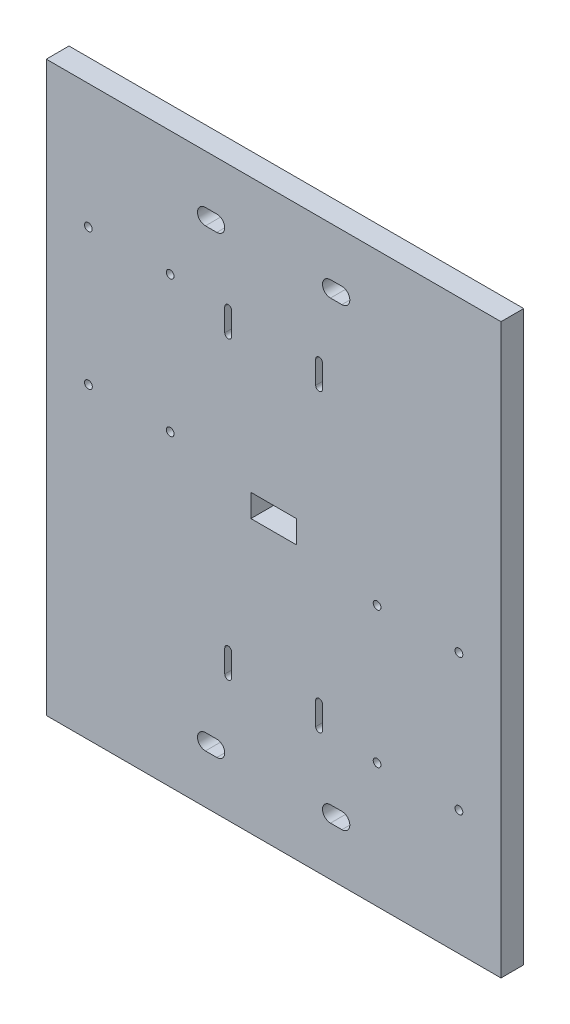
from build123d import *

# Parameters (mm, degrees)
ESQUISSE2_W             = 200
ESQUISSE2_H             = 250
BOSS_EXTRU_1_DEPTH      = 10
ESQUISSE7_W             = 20
ESQUISSE7_H             = 10
ENL_V_MAT_EXTRU_2_DEPTH = 10
ENL_V_MAT_EXTRU_3_DEPTH = 10
ENL_V_MAT_EXTRU_4_DEPTH = 10
D_GAGEMENT_M31_D        = 3.4


with BuildPart() as part:
    # Esquisse2 → Boss.-Extru.1 (new body)
    with BuildSketch(Plane.XY):
        with Locations((100, -125)):
            Rectangle(ESQUISSE2_W, ESQUISSE2_H)
    extrude(amount=BOSS_EXTRU_1_DEPTH)

    # Esquisse7 → Enlèv. mat.-Extru.2 (cut)
    with BuildSketch(Plane(origin=(0, 0, 0), x_dir=(-1, 0, 0), z_dir=(0, 0, -1))):
        with Locations((-100, -125)):
            Rectangle(ESQUISSE7_W, ESQUISSE7_H)
    extrude(amount=-ENL_V_MAT_EXTRU_2_DEPTH, mode=Mode.SUBTRACT)

    # Esquisse10 → Enlèv. mat.-Extru.3 (cut)
    with BuildSketch(Plane(origin=(0, 0, 0), x_dir=(-1, 0, 0), z_dir=(0, 0, -1))):
        with BuildLine():
            Line((-70, -28.5), (-75, -28.5))
            ThreePointArc((-75, -28.5), (-78.5, -25), (-75, -21.5))
            Line((-75, -21.5), (-70, -21.5))
            ThreePointArc((-70, -21.5), (-66.5, -25), (-70, -28.5))
        make_face()
        with BuildLine():
            Line((-70, -228.5), (-75, -228.5))
            ThreePointArc((-75, -228.5), (-78.5, -225), (-75, -221.5))
            Line((-75, -221.5), (-70, -221.5))
            ThreePointArc((-70, -221.5), (-66.5, -225), (-70, -228.5))
        make_face()
        with BuildLine():
            Line((-130, -221.5), (-125, -221.5))
            ThreePointArc((-125, -221.5), (-121.5, -225), (-125, -228.5))
            Line((-125, -228.5), (-130, -228.5))
            ThreePointArc((-130, -228.5), (-133.5, -225), (-130, -221.5))
        make_face()
        with BuildLine():
            Line((-130, -21.5), (-125, -21.5))
            ThreePointArc((-125, -21.5), (-121.5, -25), (-125, -28.5))
            Line((-125, -28.5), (-130, -28.5))
            ThreePointArc((-130, -28.5), (-133.5, -25), (-130, -21.5))
        make_face()
    extrude(amount=-ENL_V_MAT_EXTRU_3_DEPTH, mode=Mode.SUBTRACT)

    # Esquisse11 → Enlèv. mat.-Extru.4 (cut)
    with BuildSketch(Plane(origin=(0, 0, 0), x_dir=(-1, 0, 0), z_dir=(0, 0, -1))):
        with BuildLine():
            Line((-78.5, -55), (-78.5, -65))
            ThreePointArc((-78.5, -65), (-80, -66.5), (-81.5, -65))
            Line((-81.5, -65), (-81.5, -55))
            ThreePointArc((-81.5, -55), (-80, -53.5), (-78.5, -55))
        make_face()
        with BuildLine():
            Line((-118.5, -55), (-118.5, -65))
            ThreePointArc((-118.5, -65), (-120, -66.5), (-121.5, -65))
            Line((-121.5, -65), (-121.5, -55))
            ThreePointArc((-121.5, -55), (-120, -53.5), (-118.5, -55))
        make_face()
        with BuildLine():
            Line((-121.5, -195), (-121.5, -185))
            ThreePointArc((-121.5, -185), (-120, -183.5), (-118.5, -185))
            Line((-118.5, -185), (-118.5, -195))
            ThreePointArc((-118.5, -195), (-120, -196.5), (-121.5, -195))
        make_face()
        with BuildLine():
            Line((-81.5, -195), (-81.5, -185))
            ThreePointArc((-81.5, -185), (-80, -183.5), (-78.5, -185))
            Line((-78.5, -185), (-78.5, -195))
            ThreePointArc((-78.5, -195), (-80, -196.5), (-81.5, -195))
        make_face()
    extrude(amount=-ENL_V_MAT_EXTRU_4_DEPTH, mode=Mode.SUBTRACT)

    # Dégagement M31 (through all)
    with Locations(Plane.XY.offset(10)):
        with Locations((18.5, -54.7), (54.5, -54.7), (18.545923706, -114.7), (54.5, -114.7), (145.5, -135.3), (181.5, -135.3), (145.5, -195.3), (181.5, -195.3)):
            Hole(D_GAGEMENT_M31_D / 2)


solid = part.part
